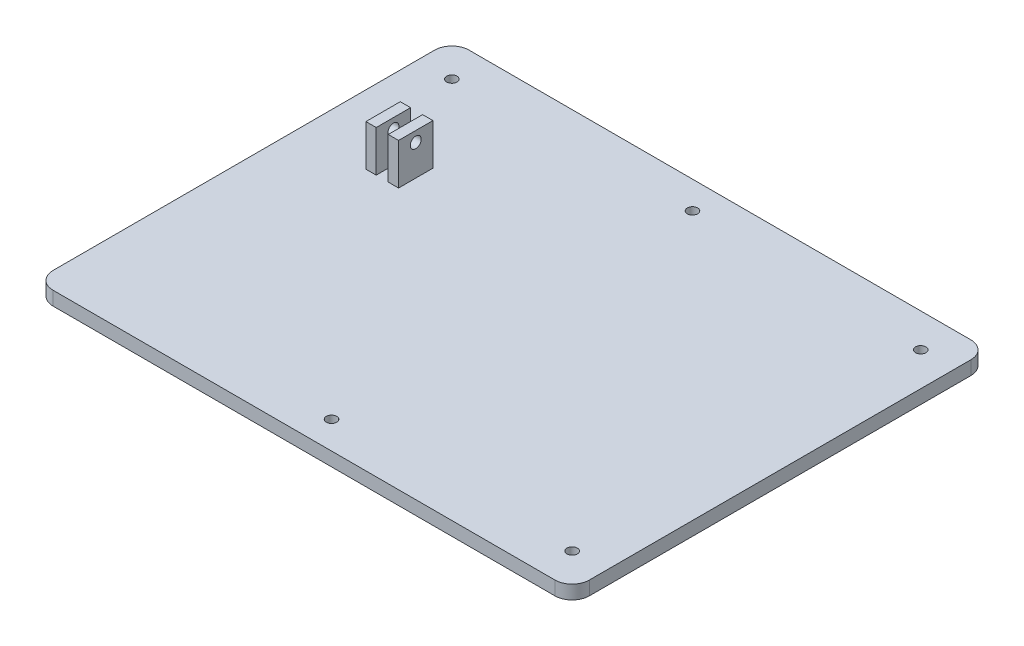
from build123d import *

# Parameters (mm, degrees)
SKETCH1_W           = 248.69467868
SKETCH1_H           = 191.562117362
BOSS_EXTRUDE1_DEPTH = 4
CUT_EXTRUDE1_DEPTH  = 10
SKETCH3_R           = 1.5
CUT_EXTRUDE2_DEPTH  = 4
SKETCH10_W          = 3
SKETCH10_H          = 10
BOSS_EXTRUDE2_DEPTH = 12
SKETCH12_R          = 1.6
CUT_EXTRUDE3_DEPTH  = 10
SKETCH13_R          = 1
CUT_EXTRUDE4_DEPTH  = 6


with BuildPart() as part:
    # Sketch1 → Boss-Extrude1 (new body)
    with BuildSketch(Plane(origin=(0, 0, 0), x_dir=(1, 0, 0), z_dir=(0, 1, 0))):
        Rectangle(SKETCH1_W, SKETCH1_H)
    extrude(amount=BOSS_EXTRUDE1_DEPTH)

    # Sketch2 → Cut-Extrude1 (cut)
    with BuildSketch(Plane(origin=(0, 4, 0), x_dir=(1, 0, 0), z_dir=(0, 1, 0))):
        with BuildLine():
            Line((-53.628035699, 20.218941319), (-53.628035699, -90.781058681))
            ThreePointArc((-53.628035699, -90.781058681), (-52.163569604, -94.316592587), (-48.628035699, -95.781058681))
            Line((-48.628035699, -95.781058681), (-124.34733934, -95.781058681))
            Line((-124.34733934, -95.781058681), (-124.34733934, 95.781058681))
            Line((-124.34733934, 95.781058681), (124.34733934, 95.781058681))
            Line((124.34733934, 95.781058681), (124.34733934, -95.781058681))
            Line((124.34733934, -95.781058681), (97.371964301, -95.781058681))
            ThreePointArc((97.371964301, -95.781058681), (100.907498207, -94.316592587), (102.371964301, -90.781058681))
            Line((102.371964301, -90.781058681), (102.371964301, 20.218941319))
            ThreePointArc((102.371964301, 20.218941319), (100.907498207, 23.754475225), (97.371964301, 25.218941319))
            Line((97.371964301, 25.218941319), (-48.628035699, 25.218941319))
            ThreePointArc((-48.628035699, 25.218941319), (-52.163569604, 23.754475225), (-53.628035699, 20.218941319))
        make_face()
    extrude(amount=-CUT_EXTRUDE1_DEPTH, mode=Mode.SUBTRACT)

    # Sketch3 → Cut-Extrude2 (cut)
    with BuildSketch(Plane(origin=(0, 4, 0), x_dir=(1, 0, 0), z_dir=(0, 1, 0))):
        with Locations((-43.82473484, 15.41564046)):
            Circle(SKETCH3_R)
        with Locations((24.371964301, 17.218941319)):
            Circle(SKETCH3_R)
        with Locations((92.568663443, 15.41564046)):
            Circle(SKETCH3_R)
        with Locations((24.371964301, -87.781058681)):
            Circle(SKETCH3_R)
        with Locations((92.568663443, -85.977757822)):
            Circle(SKETCH3_R)
    extrude(amount=-CUT_EXTRUDE2_DEPTH, mode=Mode.SUBTRACT)

    # Sketch10 → Boss-Extrude2 (add)
    with BuildSketch(Plane(origin=(0, 4, 0), x_dir=(1, 0, 0), z_dir=(0, 1, 0))):
        with Locations((-32.128035699, -14.781058681)):
            Rectangle(SKETCH10_W, SKETCH10_H)
        with Locations((-25.628035699, -14.781058681)):
            Rectangle(SKETCH10_W, SKETCH10_H)
    extrude(amount=BOSS_EXTRUDE2_DEPTH)

    # Sketch12 → Cut-Extrude3 (cut)
    with BuildSketch(Plane.ZY.offset(33.628035699)):
        with Locations((14.781058681, 13)):
            Circle(SKETCH12_R)
    extrude(amount=-CUT_EXTRUDE3_DEPTH, mode=Mode.SUBTRACT)

    # Sketch13 → Cut-Extrude4 (cut)
    with BuildSketch(Plane(origin=(0, 4, 0), x_dir=(1, 0, 0), z_dir=(0, 1, 0))):
        with Locations((-29.127206005, -15.029218682)):
            Circle(SKETCH13_R)
    extrude(amount=-CUT_EXTRUDE4_DEPTH, mode=Mode.SUBTRACT)


solid = part.part
